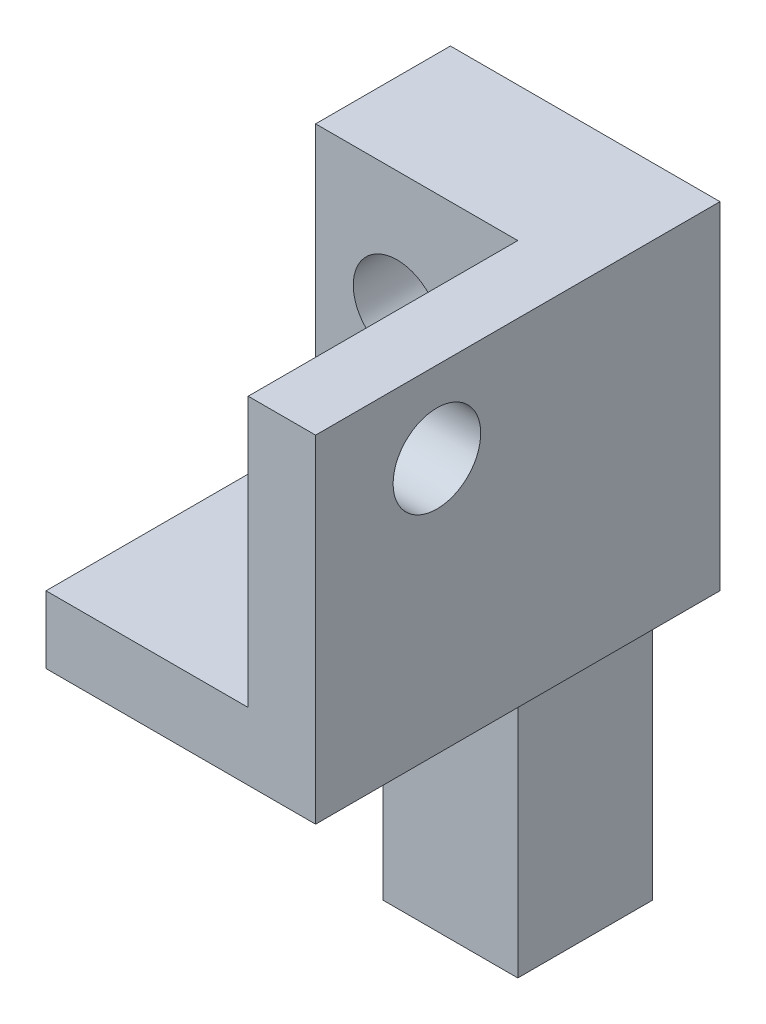
from build123d import *

# Parameters (mm, degrees)
BOSS_EXTRUDE1_DEPTH     = 10
BOSS_EXTRUDE5_DEPTH     = 5
SKETCH3_W               = 30
SKETCH3_H               = 25
BOSS_EXTRUDE6_DEPTH     = 5
SKETCH4_R               = 3.25
CUT_EXTRUDE1_DEPTH      = 22
CUT_EXTRUDE1_DEPTH_BACK = 17
SKETCH5_R               = 3.25
CUT_EXTRUDE2_DEPTH      = 16
CUT_EXTRUDE2_DEPTH_BACK = 20


with BuildPart() as part:
    # Sketch1 → Boss-Extrude1 (new body)
    with BuildSketch(Plane(origin=(0, 0, 0), x_dir=(0, 0, -1), z_dir=(1, 0, 0))):
        Polygon((0, 0), (-10, 0), (-10, -20), (-30, -20), (-30, -25), (-10, -25), (-10, -47.38), (0, -47.38), align=None)
    extrude(amount=BOSS_EXTRUDE1_DEPTH)

    # Sketch2 → Boss-Extrude5 (add)
    with BuildSketch(Plane.ZY):
        Polygon((0, 0), (10, 0), (10, -20), (30, -20), (30, -25), (0, -25), align=None)
    extrude(amount=BOSS_EXTRUDE5_DEPTH)

    # Sketch3 → Boss-Extrude6 (add)
    with BuildSketch(Plane(origin=(10, 0, 0), x_dir=(0, 0, -1), z_dir=(1, 0, 0))):
        with Locations((-15, -12.5)):
            Rectangle(SKETCH3_W, SKETCH3_H)
    extrude(amount=BOSS_EXTRUDE6_DEPTH)

    # Sketch4 → Cut-Extrude1 (cut, two sides)
    with BuildSketch(Plane(origin=(0, 0, 0), x_dir=(-1, 0, 0), z_dir=(0, 0, -1))) as cut_extrude1_sk:
        with Locations((-1.044087289, -8.964075593)):
            Circle(SKETCH4_R)
    extrude(amount=CUT_EXTRUDE1_DEPTH, mode=Mode.SUBTRACT)
    extrude(cut_extrude1_sk.sketch, amount=-CUT_EXTRUDE1_DEPTH_BACK, mode=Mode.SUBTRACT)

    # Sketch5 → Cut-Extrude2 (cut, two sides)
    with BuildSketch(Plane(origin=(15, 0, 0), x_dir=(0, 0, -1), z_dir=(1, 0, 0))) as cut_extrude2_sk:
        with Locations((-21, -6)):
            Circle(SKETCH5_R)
    extrude(amount=CUT_EXTRUDE2_DEPTH, mode=Mode.SUBTRACT)
    extrude(cut_extrude2_sk.sketch, amount=-CUT_EXTRUDE2_DEPTH_BACK, mode=Mode.SUBTRACT)


solid = part.part
